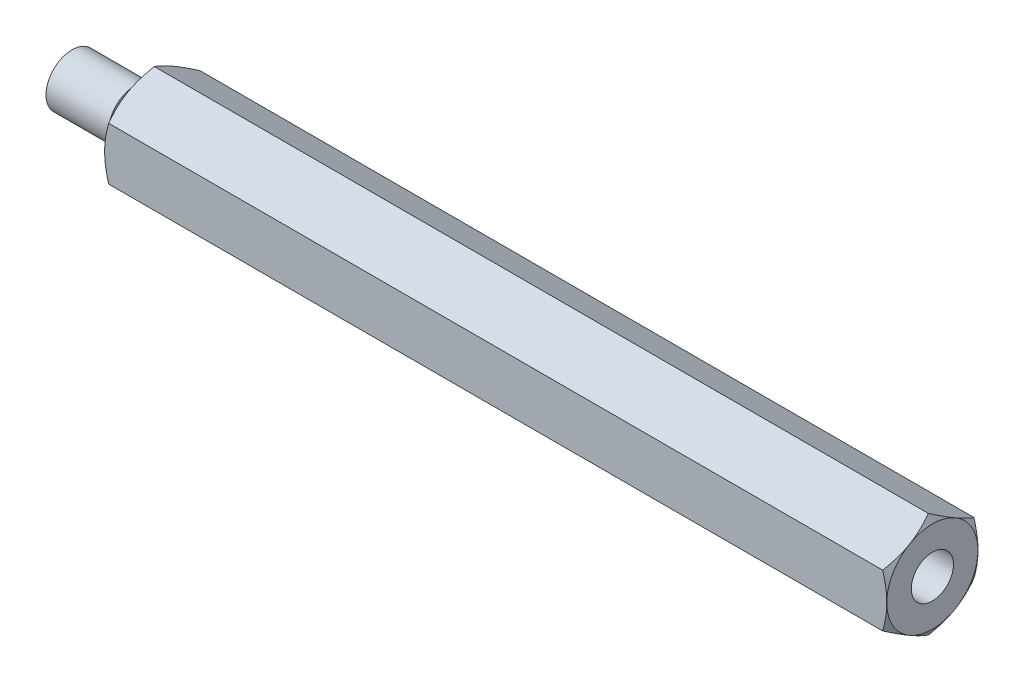
from build123d import *

# Parameters (mm, degrees)
BOSS_EXTRUDE1_DEPTH = 60
TAP2_D              = 3.242
TAP2_DEPTH          = 10.1
TAP2_TIP            = 0.973995063


with BuildPart() as part:
    # Sketch1 → Boss-Extrude1 (new body)
    with BuildSketch(Plane(origin=(0, 0, 0), x_dir=(0, 0, -1), z_dir=(1, 0, 0))):
        Polygon((0, 4.041451884), (-3.5, 2.020725942), (-3.5, -2.020725942), (0, -4.041451884), (3.5, -2.020725942), (3.5, 2.020725942), align=None)
    extrude(amount=BOSS_EXTRUDE1_DEPTH)

    # Sketch2 → Cut-Revolve1 (revolve, cut)
    with BuildSketch(Plane.XY):
        Polygon((0, 4.041451884), (0, 3.5), (0.312607391, 4.041451884), align=None)
        Polygon((59.687392609, 4.041451884), (60, 4.041451884), (60, 3.5), align=None)
    revolve(axis=Axis((0, 0, 0), (1, 0, 0)), mode=Mode.SUBTRACT)

    # Sketch6 → Revolve2 (revolve)
    with BuildSketch(Plane.XY):
        Polygon((0, 0), (0, 1.6), (-1.2, 1.6), (-1.2, 2), (-6, 2), (-6, 0), align=None)
    revolve(axis=Axis((0, 0, 0), (-1, 0, 0)))

    # Tap2
    with Locations(Plane(origin=(60, 0, 0), x_dir=(0, 0, -1), z_dir=(1, 0, 0))):
        with Locations((0, 0)):
            Hole(TAP2_D / 2, depth=TAP2_DEPTH)
            with Locations((0, 0, -(TAP2_DEPTH + TAP2_TIP / 2))):  # 118° drill point
                Cone(0, TAP2_D / 2, TAP2_TIP, mode=Mode.SUBTRACT)


solid = part.part
